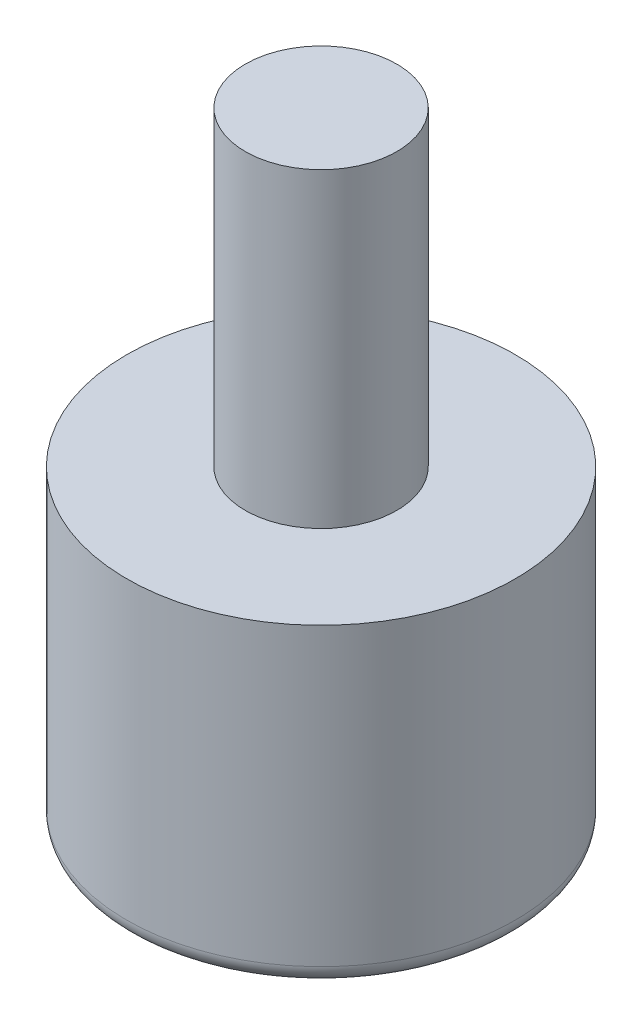
from build123d import *

# Parameters (mm, degrees)
CONG_1_R = 1


with BuildPart() as part:
    # Esquisse1 → Révolution1 (revolve)
    with BuildSketch(Plane.XY):
        with BuildLine():
            Line((10.25, 0), (6, 0))
            ThreePointArc((6, 0), (3.44818793, -2.490919876), (0, -3.4))
            Line((0, -3.4), (0, 0))
            Line((0, 0), (0, 33))
            Line((0, 33), (4, 33))
            Line((4, 33), (4, 16.6))
            Line((4, 16.6), (10.25, 16.6))
            Line((10.25, 16.6), (10.25, 0))
        make_face()
    revolve(axis=Axis((0, 33, 0), (0, -1, 0)))

    # Congé1
    cong_1_edges = [part.edges().sort_by_distance(p)[0] for p in [
        (-10.25, 0, 0),
    ]]
    fillet(cong_1_edges, radius=CONG_1_R)


solid = part.part
